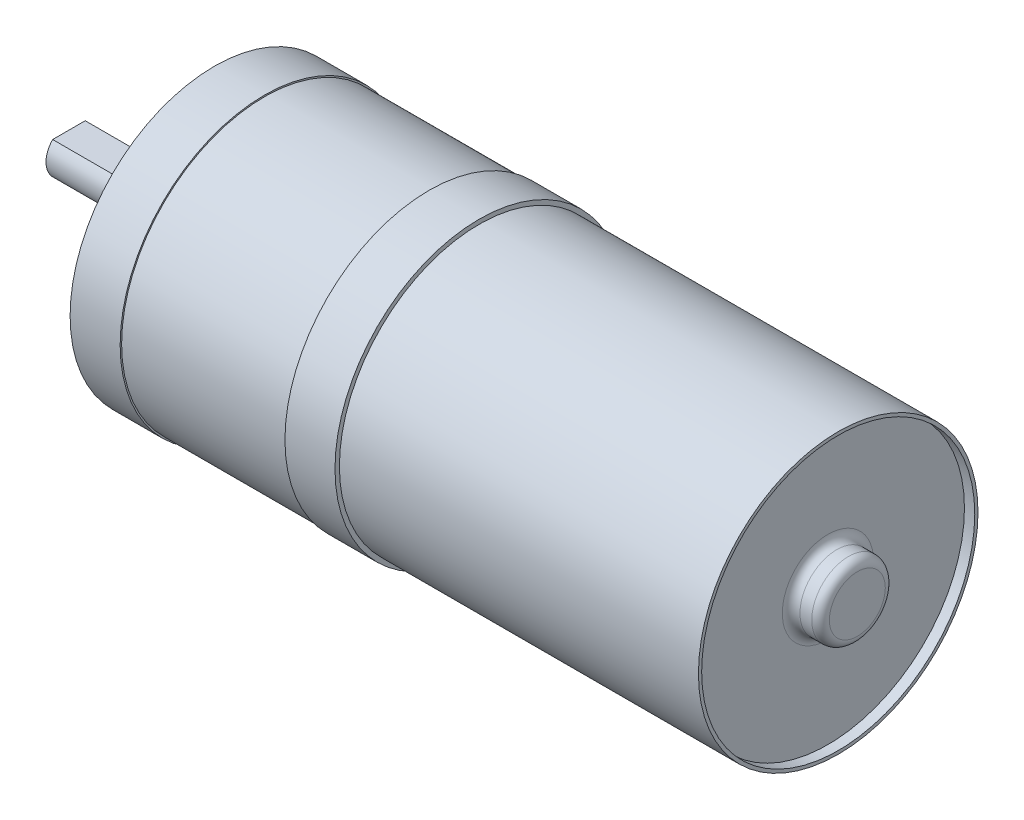
from build123d import *

# Parameters (mm, degrees)
SKETCH1_R           = 12.065
BOSS_EXTRUDE1_DEPTH = 30.988
SKETCH2_R           = 12.446
BOSS_EXTRUDE2_DEPTH = 4.318
SKETCH3_R           = 12.319
BOSS_EXTRUDE3_DEPTH = 14.224
SKETCH4_R           = 12.446
BOSS_EXTRUDE4_DEPTH = 4.318
SKETCH5_R           = 3.5052
BOSS_EXTRUDE5_DEPTH = 2.54
SKETCH6_R           = 1.9812
BOSS_EXTRUDE6_DEPTH = 10.0076
CUT_EXTRUDE1_DEPTH  = 7.9248
SKETCH8_R           = 11.7856
CUT_EXTRUDE2_DEPTH  = 0.889
SKETCH9_R           = 3.175
BOSS_EXTRUDE7_DEPTH = 2.54
FILLET1_R           = 0.762
SKETCH10_R          = 1.397
CUT_EXTRUDE3_DEPTH  = 4.7498


with BuildPart() as part:
    # Sketch1 → Boss-Extrude1 (new body)
    with BuildSketch(Plane(origin=(0, 0, 0), x_dir=(0, 0, -1), z_dir=(1, 0, 0))):
        Circle(SKETCH1_R)
    extrude(amount=BOSS_EXTRUDE1_DEPTH)

    # Sketch2 → Boss-Extrude2 (add)
    with BuildSketch(Plane.ZY):
        Circle(SKETCH2_R)
    extrude(amount=BOSS_EXTRUDE2_DEPTH)

    # Sketch3 → Boss-Extrude3 (add)
    with BuildSketch(Plane.ZY.offset(4.318)):
        Circle(SKETCH3_R)
    extrude(amount=BOSS_EXTRUDE3_DEPTH)

    # Sketch4 → Boss-Extrude4 (add)
    with BuildSketch(Plane.ZY.offset(18.542)):
        Circle(SKETCH4_R)
    extrude(amount=BOSS_EXTRUDE4_DEPTH)

    # Sketch5 → Boss-Extrude5 (add)
    with BuildSketch(Plane.ZY.offset(22.86)):
        Circle(SKETCH5_R)
    extrude(amount=BOSS_EXTRUDE5_DEPTH)

    # Sketch6 → Boss-Extrude6 (add)
    with BuildSketch(Plane.ZY.offset(25.4)):
        Circle(SKETCH6_R)
    extrude(amount=BOSS_EXTRUDE6_DEPTH)

    # Sketch7 → Cut-Extrude1 (cut)
    with BuildSketch(Plane.ZY.offset(35.4076)):
        with BuildLine():
            Line((-1.404828972, 1.397), (1.404828972, 1.397))
            ThreePointArc((1.404828972, 1.397), (0, 1.9812), (-1.404828972, 1.397))
        make_face()
    extrude(amount=-CUT_EXTRUDE1_DEPTH, mode=Mode.SUBTRACT)

    # Sketch8 → Cut-Extrude2 (cut)
    with BuildSketch(Plane(origin=(30.988, 0, 0), x_dir=(0, 0, -1), z_dir=(1, 0, 0))):
        Circle(SKETCH8_R)
    extrude(amount=-CUT_EXTRUDE2_DEPTH, mode=Mode.SUBTRACT)

    # Sketch9 → Boss-Extrude7 (add)
    with BuildSketch(Plane(origin=(30.099, 0, 0), x_dir=(0, 0, -1), z_dir=(1, 0, 0))):
        Circle(SKETCH9_R)
    extrude(amount=BOSS_EXTRUDE7_DEPTH)

    # Fillet1
    fillet1_edges = [part.edges().sort_by_distance(p)[0] for p in [
        (30.099, 0, 3.175),
        (32.639, 0, 3.175),
    ]]
    fillet(fillet1_edges, radius=FILLET1_R)

    # Sketch10 → Cut-Extrude3 (cut)
    with BuildSketch(Plane.ZY.offset(22.86)):
        with Locations((8.509, 0)):
            Circle(SKETCH10_R)
        with Locations((-8.509, 0)):
            Circle(SKETCH10_R)
    extrude(amount=-CUT_EXTRUDE3_DEPTH, mode=Mode.SUBTRACT)


solid = part.part
